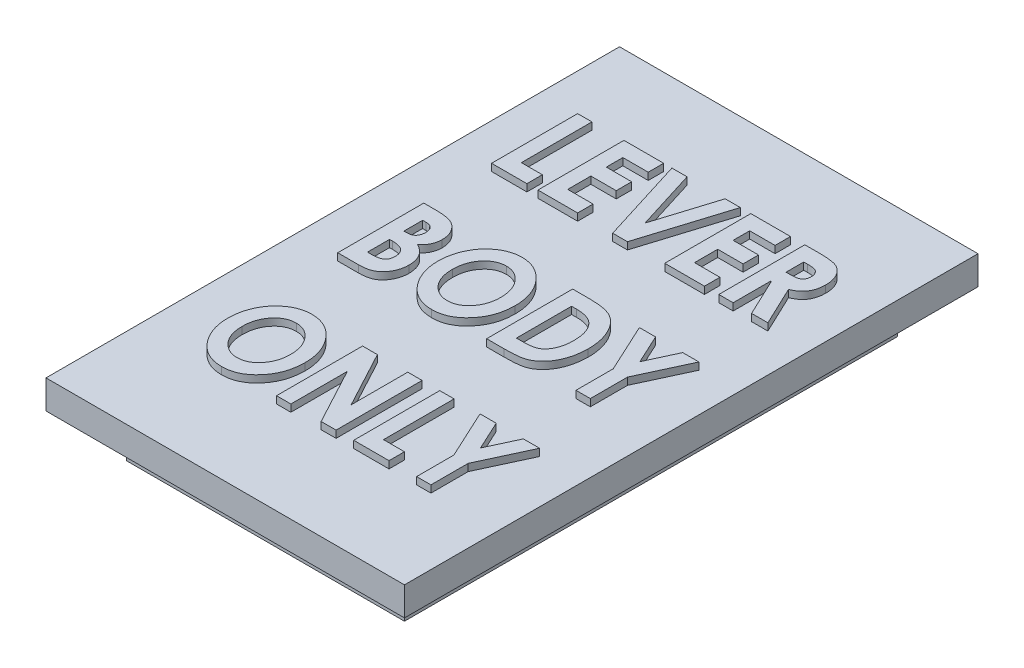
from build123d import *

# Parameters (mm, degrees)
SKETCH1_W           = 19.4
SKETCH1_H           = 34.4
BOSS_EXTRUDE1_DEPTH = 3
SKETCH2_W           = 25
SKETCH2_H           = 40
BOSS_EXTRUDE2_DEPTH = 2
BOSS_EXTRUDE3_DEPTH = 0.5


with BuildPart() as part:
    # Sketch1 → Boss-Extrude1 (new body)
    with BuildSketch(Plane(origin=(0, 0, 0), x_dir=(1, 0, 0), z_dir=(0, 1, 0))):
        Rectangle(SKETCH1_W, SKETCH1_H)
    extrude(amount=BOSS_EXTRUDE1_DEPTH)

    # Sketch2 → Boss-Extrude2 (add)
    with BuildSketch(Plane(origin=(0, 3, 0), x_dir=(1, 0, 0), z_dir=(0, 1, 0))):
        Rectangle(SKETCH2_W, SKETCH2_H)
    extrude(amount=BOSS_EXTRUDE2_DEPTH)

    # Sketch3 → Boss-Extrude3 (add)
    with BuildSketch(Plane(origin=(0, 5, 0), x_dir=(1, 0, 0), z_dir=(0, 1, 0))):
        Polygon((-9.423076923, 14), (-8.423076923, 14), (-8.423076923, 9.076923077), (-6.961538462, 9.076923077), (-6.961538462, 8), (-9.423076923, 8), align=None)
        Polygon((-6.192307692, 14), (-3.423076923, 14), (-3.423076923, 12.923076923), (-5.192307692, 12.923076923), (-5.192307692, 11.769230769), (-3.423076923, 11.769230769), (-3.423076923, 10.692307692), (-5.192307692, 10.692307692), (-5.192307692, 9.076923077), (-3.423076923, 9.076923077), (-3.423076923, 8), (-6.192307692, 8), align=None)
        Polygon((-2.846153846, 14), (-1.788461538, 14), (-0.461538462, 9.737980769), (0.867788462, 14), (1.923076923, 14), (0.051682692, 8), (-0.977163462, 8), align=None)
        Polygon((2.653846154, 14), (5.423076923, 14), (5.423076923, 12.923076923), (3.653846154, 12.923076923), (3.653846154, 11.769230769), (5.423076923, 11.769230769), (5.423076923, 10.692307692), (3.653846154, 10.692307692), (3.653846154, 9.076923077), (5.423076923, 9.076923077), (5.423076923, 8), (2.653846154, 8), align=None)
        with BuildLine():
            Line((6.423076923, 14), (7.495192308, 14))
            add(Edge.make_bspline(
                [(7.495192308, 14), (7.565716082, 13.999692793), (7.702010779, 13.999099082), (7.898391471, 13.990259019), (8.079272988, 13.977728257), (8.244156273, 13.958758313), (8.393014185, 13.933838236), (8.526193833, 13.903624533), (8.644139743, 13.87011321), (8.779050299, 13.815187629), (8.930257846, 13.729159202), (9.092102694, 13.597787753), (9.233816486, 13.436238489), (9.355507645, 13.248692243), (9.455996707, 13.038283275), (9.526259048, 12.806550176), (9.56898116, 12.556866273), (9.574225501, 12.384390756), (9.576923077, 12.295673077)],
                knots=[0, 0, 0, 0, 0.000211552, 0.000408847, 0.00058962, 0.000755402, 0.000906563, 0.001042146, 0.001164983, 0.001273902, 0.001478441, 0.001684363, 0.001896369, 0.002120391, 0.002353186, 0.002593456, 0.002844601, 0.003110617, 0.003110617, 0.003110617, 0.003110617], degree=3))
            add(Edge.make_bspline(
                [(9.576923077, 12.295673077), (9.57634034, 12.248372382), (9.575197559, 12.155612924), (9.562997288, 12.019467998), (9.542424057, 11.889473187), (9.514918602, 11.764865894), (9.479415699, 11.64605475), (9.433945253, 11.533657974), (9.383200458, 11.42639336), (9.322007668, 11.325942603), (9.254082633, 11.231148047), (9.177195351, 11.142737763), (9.093581116, 11.059422992), (8.999749925, 10.983791093), (8.898931748, 10.912490949), (8.789272857, 10.848096085), (8.672313049, 10.788408867), (8.590015205, 10.755003739), (8.548076923, 10.737980769)],
                knots=[0, 0, 0, 0, 0.000141873, 0.000278221, 0.000409627, 0.000536474, 0.000660808, 0.000781108, 0.00089991, 0.001016373, 0.00113346, 0.001249357, 0.001367494, 0.001487072, 0.001610449, 0.001737632, 0.001868249, 0.002003976, 0.002003976, 0.002003976, 0.002003976], degree=3))
            Line((8.548076923, 10.737980769), (9.846153846, 8))
            Line((9.846153846, 8), (8.710336538, 8))
            Line((8.710336538, 8), (7.469951923, 10.615384615))
            Line((7.469951923, 10.615384615), (7.423076923, 10.615384615))
            Line((7.423076923, 10.615384615), (7.423076923, 8))
            Line((7.423076923, 8), (6.423076923, 8))
            Line((6.423076923, 8), (6.423076923, 14))
        make_face()
        with BuildLine():
            Line((7.423076923, 11.692307692), (7.737980769, 11.692307692))
            add(Edge.make_bspline(
                [(7.737980769, 11.692307692), (7.776444427, 11.692888957), (7.850215642, 11.69400379), (7.95624872, 11.699097626), (8.052470782, 11.711523783), (8.139483597, 11.727213836), (8.218081269, 11.745218745), (8.286524629, 11.771018343), (8.346488021, 11.799230102), (8.41266021, 11.84465353), (8.481983468, 11.916603886), (8.538731233, 12.028063417), (8.572097584, 12.161949108), (8.575245837, 12.258603368), (8.576923077, 12.310096154)],
                knots=[0, 0, 0, 0, 0.00011541, 0.000221349, 0.000318252, 0.000406189, 0.000486646, 0.000559658, 0.000625237, 0.000684911, 0.000799674, 0.000920645, 0.001055908, 0.001210134, 0.001210134, 0.001210134, 0.001210134], degree=3))
            add(Edge.make_bspline(
                [(8.576923077, 12.310096154), (8.575743875, 12.341827369), (8.573442756, 12.403748342), (8.556284171, 12.493096474), (8.528812603, 12.576443972), (8.488732703, 12.651576163), (8.440824607, 12.719628017), (8.38404366, 12.777722916), (8.3195226, 12.825220132), (8.244050024, 12.863789384), (8.148509814, 12.891389305), (8.025928454, 12.910559882), (7.87239739, 12.921700941), (7.759634934, 12.92259225), (7.698317308, 12.923076923)],
                knots=[0, 0, 0, 0, 9.5142e-05, 0.000185662, 0.000271941, 0.000357422, 0.000440136, 0.00052088, 0.00059997, 0.000679524, 0.000773812, 0.000896914, 0.001051229, 0.001235158, 0.001235158, 0.001235158, 0.001235158], degree=3))
            Line((7.698317308, 12.923076923), (7.423076923, 12.923076923))
            Line((7.423076923, 12.923076923), (7.423076923, 11.692307692))
        make_face(mode=Mode.SUBTRACT)
        with BuildLine():
            Line((-9.384615385, -2.769230769), (-9.384615385, 3.230769231))
            Line((-9.384615385, 3.230769231), (-8.575721154, 3.230769231))
            add(Edge.make_bspline(
                [(-8.575721154, 3.230769231), (-8.519223397, 3.230779244), (-8.409797524, 3.230798639), (-8.251527984, 3.224137387), (-8.1048841, 3.21575209), (-7.970014332, 3.206007352), (-7.847487459, 3.189714384), (-7.736666137, 3.172301881), (-7.637370877, 3.151126425), (-7.576018233, 3.13259888), (-7.546875, 3.123798077)],
                knots=[0, 0, 0, 0, 0.000169475, 0.000328243, 0.000475119, 0.000610168, 0.000733756, 0.000845793, 0.000946697, 0.001037996, 0.001037996, 0.001037996, 0.001037996], degree=3))
            add(Edge.make_bspline(
                [(-7.546875, 3.123798077), (-7.50895312, 3.111263932), (-7.433889188, 3.086453395), (-7.326939058, 3.037596266), (-7.225590471, 2.982344728), (-7.129952113, 2.91969153), (-7.040650895, 2.848451795), (-6.957806657, 2.76882825), (-6.880642941, 2.682016213), (-6.809888719, 2.588393857), (-6.746163543, 2.488843349), (-6.691041525, 2.384164115), (-6.643730514, 2.27538287), (-6.605222336, 2.161999231), (-6.575442917, 2.044201303), (-6.55329253, 1.922185523), (-6.541792023, 1.795492904), (-6.539584043, 1.709554987), (-6.538461538, 1.665865385)],
                knots=[0, 0, 0, 0, 0.000119741, 0.000237019, 0.000352128, 0.000465803, 0.000579555, 0.000694318, 0.000810103, 0.000927652, 0.001046015, 0.0011643, 0.001282192, 0.00140154, 0.001523101, 0.001646408, 0.001773181, 0.001904279, 0.001904279, 0.001904279, 0.001904279], degree=3))
            add(Edge.make_bspline(
                [(-6.538461538, 1.665865385), (-6.54014369, 1.609696432), (-6.543451703, 1.499238068), (-6.567568843, 1.337455146), (-6.608999868, 1.183701436), (-6.665359697, 1.036786187), (-6.741253748, 0.895929761), (-6.83855043, 0.761798645), (-6.954664737, 0.630153137), (-7.044734275, 0.550721859), (-7.091346154, 0.509615385)],
                knots=[0, 0, 0, 0, 0.000168479, 0.000331321, 0.000489341, 0.00064536, 0.000802389, 0.000967818, 0.001141495, 0.001327778, 0.001327778, 0.001327778, 0.001327778], degree=3))
            add(Edge.make_bspline(
                [(-7.091346154, 0.509615385), (-7.051817001, 0.488039316), (-6.974329897, 0.445744783), (-6.864843951, 0.375730957), (-6.763143382, 0.30209537), (-6.669513415, 0.224658462), (-6.585120992, 0.141952308), (-6.50742828, 0.056843737), (-6.439049013, -0.033518199), (-6.35862584, -0.159121332), (-6.275357097, -0.328043204), (-6.204521409, -0.547378676), (-6.161764955, -0.784402781), (-6.156537908, -0.948135201), (-6.153846154, -1.032451923)],
                knots=[0, 0, 0, 0, 0.000135071, 0.000264773, 0.000389547, 0.000511582, 0.000628879, 0.000743768, 0.000856992, 0.00096835, 0.001190884, 0.001419698, 0.001657818, 0.001910634, 0.001910634, 0.001910634, 0.001910634], degree=3))
            add(Edge.make_bspline(
                [(-6.153846154, -1.032451923), (-6.156594668, -1.114374148), (-6.162007816, -1.275718466), (-6.205603009, -1.511862417), (-6.274976299, -1.737619757), (-6.373689267, -1.948466839), (-6.492493121, -2.141473397), (-6.630267328, -2.310195479), (-6.784600771, -2.453005097), (-6.927536116, -2.550326258), (-7.051341578, -2.615741234), (-7.154037336, -2.655032792), (-7.263266757, -2.692615296), (-7.382457851, -2.718769322), (-7.508966525, -2.742305299), (-7.644750132, -2.757242352), (-7.788316244, -2.767039015), (-7.887001552, -2.768488864), (-7.9375, -2.769230769)],
                knots=[0, 0, 0, 0, 0.000245616, 0.000483736, 0.000717911, 0.000952372, 0.001180171, 0.00139624, 0.001603786, 0.001808809, 0.001913099, 0.002023133, 0.002138298, 0.002259287, 0.002388721, 0.00252424, 0.002668791, 0.002820277, 0.002820277, 0.002820277, 0.002820277], degree=3))
            Line((-7.9375, -2.769230769), (-9.384615385, -2.769230769))
        make_face()
        with BuildLine():
            Line((-8.384615385, 2.153846154), (-8.384615385, 0.846153846))
            Line((-8.384615385, 0.846153846), (-8.1875, 0.846153846))
            add(Edge.make_bspline(
                [(-8.1875, 0.846153846), (-8.135970161, 0.847719424), (-8.038368132, 0.850684766), (-7.902730464, 0.886293702), (-7.786785678, 0.94260981), (-7.694575497, 1.024731845), (-7.624115694, 1.125730918), (-7.573233379, 1.24335541), (-7.543074265, 1.377507101), (-7.540043851, 1.472194289), (-7.538461538, 1.521634615)],
                knots=[0, 0, 0, 0, 0.000154226, 0.000292118, 0.00041736, 0.000537438, 0.000658158, 0.000784102, 0.000919685, 0.001067834, 0.001067834, 0.001067834, 0.001067834], degree=3))
            add(Edge.make_bspline(
                [(-7.538461538, 1.521634615), (-7.540052556, 1.56789856), (-7.543089778, 1.656215571), (-7.57299262, 1.780890624), (-7.619188768, 1.891842809), (-7.687807945, 1.985656031), (-7.775113175, 2.062884387), (-7.883771389, 2.117442112), (-8.012347939, 2.148305748), (-8.103989639, 2.151924748), (-8.152644231, 2.153846154)],
                knots=[0, 0, 0, 0, 0.000138555, 0.000264499, 0.000382392, 0.000496827, 0.000610121, 0.000728917, 0.000857764, 0.001003598, 0.001003598, 0.001003598, 0.001003598], degree=3))
            Line((-8.152644231, 2.153846154), (-8.384615385, 2.153846154))
        make_face(mode=Mode.SUBTRACT)
        with BuildLine():
            Line((-8.384615385, -0.153846154), (-8.384615385, -1.692307692))
            Line((-8.384615385, -1.692307692), (-8.149038462, -1.692307692))
            add(Edge.make_bspline(
                [(-8.149038462, -1.692307692), (-8.102152584, -1.691956339), (-8.011902957, -1.691280027), (-7.882664911, -1.683138923), (-7.765564262, -1.668551254), (-7.660521927, -1.650061426), (-7.567112784, -1.624886702), (-7.485660793, -1.594120202), (-7.415518355, -1.55832623), (-7.340143284, -1.501796888), (-7.264139712, -1.415306015), (-7.198036828, -1.291730914), (-7.161056072, -1.146693885), (-7.156332131, -1.044280006), (-7.153846154, -0.990384615)],
                knots=[0, 0, 0, 0, 0.000140646, 0.000270726, 0.000388201, 0.000494522, 0.00059045, 0.000677951, 0.000755371, 0.000825804, 0.000959455, 0.001097111, 0.001242588, 0.001404188, 0.001404188, 0.001404188, 0.001404188], degree=3))
            add(Edge.make_bspline(
                [(-7.153846154, -0.990384615), (-7.154522301, -0.95870714), (-7.155836009, -0.897159971), (-7.166501756, -0.807286972), (-7.186032168, -0.722879066), (-7.212126436, -0.64337779), (-7.246194974, -0.56930711), (-7.287286468, -0.500406649), (-7.335682454, -0.435985363), (-7.392431253, -0.376933657), (-7.457758736, -0.323347643), (-7.533147443, -0.277703731), (-7.618221654, -0.238872555), (-7.713680672, -0.208579186), (-7.818294802, -0.182607853), (-7.933141109, -0.167110862), (-8.057456704, -0.15554585), (-8.143798234, -0.154427681), (-8.188701923, -0.153846154)],
                knots=[0, 0, 0, 0, 9.502e-05, 0.000184618, 0.000270923, 0.00035454, 0.000435213, 0.000514984, 0.000594793, 0.000676399, 0.000760121, 0.000847523, 0.000940032, 0.001039994, 0.001147565, 0.001262981, 0.001387251, 0.001521914, 0.001521914, 0.001521914, 0.001521914], degree=3))
            Line((-8.188701923, -0.153846154), (-8.384615385, -0.153846154))
        make_face(mode=Mode.SUBTRACT)
        with BuildLine():
            add(Edge.make_bspline(
                [(-2.681490385, 3.384615385), (-2.591164255, 3.381950448), (-2.413053702, 3.376695563), (-2.150935296, 3.331641838), (-1.898422683, 3.259621782), (-1.655432938, 3.158133184), (-1.423023311, 3.026463346), (-1.199831022, 2.867405077), (-0.987681743, 2.677594102), (-0.786611524, 2.463531782), (-0.602747581, 2.228210672), (-0.440912701, 1.977818944), (-0.304958626, 1.71427333), (-0.191677454, 1.439295165), (-0.107377357, 1.150012365), (-0.044505324, 0.849166271), (-0.006361322, 0.535035636), (-0.002145075, 0.321420219), (0, 0.212740385)],
                knots=[0, 0, 0, 0, 0.000270817, 0.000534013, 0.000795362, 0.001057196, 0.001321969, 0.001595123, 0.001877797, 0.002174555, 0.002475096, 0.002772484, 0.003067612, 0.003363571, 0.003663238, 0.00397015, 0.004284863, 0.004610806, 0.004610806, 0.004610806, 0.004610806], degree=3))
            add(Edge.make_bspline(
                [(0, 0.212740385), (-0.002088915, 0.105247644), (-0.006201855, -0.106398751), (-0.045221542, -0.416976174), (-0.104295057, -0.715660813), (-0.189739524, -1.001531272), (-0.301208269, -1.27440565), (-0.435916328, -1.535008127), (-0.595885479, -1.78241769), (-0.776594377, -2.015165241), (-0.976141215, -2.226057211), (-1.186616561, -2.413170521), (-1.409169908, -2.569987921), (-1.641058163, -2.700240621), (-1.884402526, -2.800689766), (-2.138549561, -2.87168519), (-2.403181874, -2.914722806), (-2.583173366, -2.920269419), (-2.674278846, -2.923076923)],
                knots=[0, 0, 0, 0, 0.00032234, 0.000634666, 0.000937563, 0.001234926, 0.001528205, 0.001820646, 0.002113701, 0.002410868, 0.002703353, 0.002983535, 0.003254317, 0.003518502, 0.003779876, 0.004042052, 0.004308614, 0.004581831, 0.004581831, 0.004581831, 0.004581831], degree=3))
            add(Edge.make_bspline(
                [(-2.674278846, -2.923076923), (-2.769832133, -2.920581663), (-2.957607937, -2.915678122), (-3.232216693, -2.868746866), (-3.495578733, -2.798016906), (-3.744950499, -2.692976314), (-3.983023867, -2.56133545), (-4.207324744, -2.398616705), (-4.419629753, -2.207360087), (-4.61740351, -1.990106351), (-4.795603935, -1.752072268), (-4.954734891, -1.501842605), (-5.086628681, -1.23881097), (-5.195469629, -0.965337827), (-5.281246432, -0.681596897), (-5.340894687, -0.386229456), (-5.377967896, -0.08027681), (-5.382378521, 0.127697972), (-5.384615385, 0.233173077)],
                knots=[0, 0, 0, 0, 0.000286421, 0.000562858, 0.000833462, 0.001102878, 0.001372433, 0.001647964, 0.001932239, 0.002228312, 0.002527832, 0.002823283, 0.003116769, 0.00340915, 0.003705363, 0.004004726, 0.004312136, 0.004628471, 0.004628471, 0.004628471, 0.004628471], degree=3))
            add(Edge.make_bspline(
                [(-5.384615385, 0.233173077), (-5.383397255, 0.30412125), (-5.380978251, 0.445012578), (-5.363559938, 0.654028624), (-5.336563491, 0.858839828), (-5.296284183, 1.058936932), (-5.246020956, 1.254824212), (-5.184646307, 1.446827975), (-5.111243652, 1.634154789), (-5.026883646, 1.816481702), (-4.934554703, 1.992797911), (-4.829887388, 2.158617406), (-4.7198769, 2.316739867), (-4.600523611, 2.464855439), (-4.472485383, 2.603826429), (-4.336040378, 2.733242875), (-4.190674232, 2.852797057), (-4.038645393, 2.962905002), (-3.881121848, 3.062968203), (-3.717969059, 3.147598125), (-3.553359515, 3.222401666), (-3.38430353, 3.280245886), (-3.213302631, 3.328610358), (-3.038508742, 3.359704127), (-2.861149416, 3.381937947), (-2.741657833, 3.383718716), (-2.681490385, 3.384615385)],
                knots=[0, 0, 0, 0, 0.000212825, 0.000422636, 0.000628824, 0.000832248, 0.00103456, 0.001235256, 0.001436581, 0.001637716, 0.00183773, 0.002033168, 0.002225569, 0.002415344, 0.002603324, 0.002792069, 0.002979048, 0.003167535, 0.003354947, 0.003538278, 0.003718527, 0.003896805, 0.004073798, 0.004251072, 0.004428933, 0.004609321, 0.004609321, 0.004609321, 0.004609321], degree=3))
        make_face()
        with BuildLine():
            add(Edge.make_bspline(
                [(-2.695913462, 2.307692308), (-2.75452499, 2.305834514), (-2.870007443, 2.302174097), (-3.039283894, 2.273466331), (-3.20151597, 2.228568585), (-3.355706089, 2.161807002), (-3.503771585, 2.079355677), (-3.64442309, 1.977129802), (-3.776716275, 1.855993105), (-3.900931391, 1.718260122), (-4.014467278, 1.566873194), (-4.113601374, 1.403295329), (-4.197576612, 1.23024597), (-4.266814261, 1.047323784), (-4.319241261, 0.853976084), (-4.357515284, 0.651074609), (-4.380988101, 0.438052793), (-4.383388449, 0.2929296), (-4.384615385, 0.21875)],
                knots=[0, 0, 0, 0, 0.000175744, 0.000346269, 0.000513677, 0.000679547, 0.000849057, 0.001021196, 0.001199875, 0.001386235, 0.00157686, 0.001766707, 0.00195915, 0.00215314, 0.002352587, 0.002559321, 0.002772089, 0.002994562, 0.002994562, 0.002994562, 0.002994562], degree=3))
            add(Edge.make_bspline(
                [(-4.384615385, 0.21875), (-4.382848022, 0.136530174), (-4.379388111, -0.024428948), (-4.350074025, -0.258969355), (-4.30251585, -0.480508231), (-4.234317519, -0.688288922), (-4.150087364, -0.88446937), (-4.042530646, -1.065108406), (-3.919200163, -1.234959431), (-3.821053231, -1.334496708), (-3.771634615, -1.384615385)],
                knots=[0, 0, 0, 0, 0.000246582, 0.000482725, 0.00070787, 0.000925282, 0.001137873, 0.001346897, 0.001554833, 0.001765715, 0.001765715, 0.001765715, 0.001765715], degree=3))
            add(Edge.make_bspline(
                [(-3.771634615, -1.384615385), (-3.731837841, -1.421463544), (-3.653562156, -1.493939642), (-3.526612245, -1.587353146), (-3.396276722, -1.667705174), (-3.260952816, -1.732953736), (-3.121161001, -1.783563638), (-2.97703852, -1.819784526), (-2.828822436, -1.842065954), (-2.728442066, -1.844784584), (-2.677884615, -1.846153846)],
                knots=[0, 0, 0, 0, 0.000162598, 0.000319811, 0.000471938, 0.000621383, 0.000769664, 0.000917168, 0.001066579, 0.001218193, 0.001218193, 0.001218193, 0.001218193], degree=3))
            add(Edge.make_bspline(
                [(-2.677884615, -1.846153846), (-2.620885262, -1.844245159), (-2.508212271, -1.840472179), (-2.342268753, -1.812214094), (-2.183016444, -1.765133757), (-2.029993616, -1.69961398), (-1.883813441, -1.615024297), (-1.745177404, -1.510334429), (-1.612583561, -1.388162178), (-1.487284322, -1.249529618), (-1.372515629, -1.096951333), (-1.273069628, -0.933153092), (-1.187772272, -0.761321431), (-1.119851565, -0.5802274), (-1.065042059, -0.390695041), (-1.02731772, -0.192322527), (-1.003616847, 0.014644912), (-1.001221641, 0.155382335), (-1, 0.227163462)],
                knots=[0, 0, 0, 0, 0.000170944, 0.000337912, 0.000503345, 0.00066811, 0.000836125, 0.001008722, 0.001188211, 0.001376269, 0.001568577, 0.001760075, 0.001950359, 0.002143225, 0.002339526, 0.002541538, 0.002748332, 0.002963597, 0.002963597, 0.002963597, 0.002963597], degree=3))
            add(Edge.make_bspline(
                [(-1, 0.227163462), (-1.001105024, 0.298556519), (-1.003278245, 0.438963358), (-1.028748392, 0.644997304), (-1.0664444, 0.842942952), (-1.120638738, 1.032478462), (-1.190901893, 1.213154832), (-1.274756083, 1.386500691), (-1.376722309, 1.549839608), (-1.491105558, 1.704321996), (-1.617047299, 1.844833153), (-1.751263235, 1.96814392), (-1.890660109, 2.074335652), (-2.03900953, 2.158822306), (-2.19380645, 2.225419685), (-2.355330999, 2.274048129), (-2.523872091, 2.301928637), (-2.638121272, 2.305756174), (-2.695913462, 2.307692308)],
                knots=[0, 0, 0, 0, 0.000214064, 0.000420994, 0.000621826, 0.000818127, 0.001011423, 0.001202786, 0.001394913, 0.001588184, 0.001778832, 0.001960019, 0.002134298, 0.002303355, 0.002470803, 0.002638883, 0.002808222, 0.002981566, 0.002981566, 0.002981566, 0.002981566], degree=3))
        make_face(mode=Mode.SUBTRACT)
        with BuildLine():
            Line((1, 3.230769231), (2.181490385, 3.230769231))
            add(Edge.make_bspline(
                [(2.181490385, 3.230769231), (2.273662624, 3.230018527), (2.452140179, 3.228564904), (2.710393115, 3.212571589), (2.950653338, 3.187617422), (3.172775389, 3.153620317), (3.376600674, 3.108521827), (3.561638159, 3.05160638), (3.728999806, 2.986467723), (3.880031096, 2.909529867), (4.017349051, 2.819759858), (4.147970469, 2.719779993), (4.271681185, 2.606635016), (4.388706925, 2.480272395), (4.500930858, 2.342416004), (4.604733453, 2.18979083), (4.704961156, 2.026743274), (4.797156201, 1.851227775), (4.880823071, 1.665888942), (4.954755281, 1.471876669), (5.015462019, 1.269605012), (5.066095374, 1.059771897), (5.105913195, 0.842333654), (5.132906697, 0.617126484), (5.150311385, 0.384488016), (5.152654886, 0.226794608), (5.153846154, 0.146634615)],
                knots=[0, 0, 0, 0, 0.000276484, 0.00053537, 0.00077588, 0.001000951, 0.001209148, 0.001401523, 0.001581194, 0.001747294, 0.001908987, 0.002072701, 0.002240303, 0.002411234, 0.002588997, 0.002773032, 0.002964531, 0.003162921, 0.003367336, 0.00357427, 0.003785292, 0.004000433, 0.004221567, 0.00444802, 0.004680601, 0.004921061, 0.004921061, 0.004921061, 0.004921061], degree=3))
            add(Edge.make_bspline(
                [(5.153846154, 0.146634615), (5.151858115, 0.0335282), (5.14794752, -0.188959076), (5.107595895, -0.515181604), (5.046576806, -0.828522164), (4.956701758, -1.12497884), (4.849292817, -1.403902526), (4.718727466, -1.65833924), (4.570766889, -1.889446894), (4.402666348, -2.092582074), (4.222578494, -2.269348115), (4.034564982, -2.419299158), (3.837412, -2.538191847), (3.663126617, -2.613768166), (3.512198318, -2.660756161), (3.380002074, -2.688298026), (3.229732437, -2.713866892), (3.059947294, -2.733240761), (2.871672849, -2.750750502), (2.664333302, -2.760272298), (2.438361617, -2.768142464), (2.281258764, -2.768858316), (2.199519231, -2.769230769)],
                knots=[0, 0, 0, 0, 0.000339155, 0.000667139, 0.00098465, 0.001295713, 0.001595243, 0.001880139, 0.002152181, 0.002416877, 0.002669306, 0.002908078, 0.003136674, 0.003357939, 0.003476174, 0.003610322, 0.003762668, 0.003933366, 0.004122817, 0.00432983, 0.004555907, 0.004801111, 0.004801111, 0.004801111, 0.004801111], degree=3))
            Line((2.199519231, -2.769230769), (1, -2.769230769))
            Line((1, -2.769230769), (1, 3.230769231))
        make_face()
        with BuildLine():
            Line((2, 2.153846154), (2, -1.692307692))
            Line((2, -1.692307692), (2.462740385, -1.692307692))
            add(Edge.make_bspline(
                [(2.462740385, -1.692307692), (2.517653835, -1.692166734), (2.623967915, -1.691893834), (2.777362761, -1.680756617), (2.919664819, -1.669431542), (3.049398849, -1.647969499), (3.168061034, -1.624329888), (3.273752663, -1.590478331), (3.369877214, -1.556115388), (3.481114883, -1.497199737), (3.607248397, -1.404370036), (3.741252593, -1.263984054), (3.861057484, -1.092879835), (3.964545896, -0.891987897), (4.049849511, -0.663479533), (4.110131458, -0.408786759), (4.148024536, -0.12974435), (4.151855283, 0.064773085), (4.153846154, 0.165865385)],
                knots=[0, 0, 0, 0, 0.000164681, 0.000318827, 0.000461269, 0.000592675, 0.000713138, 0.000823773, 0.000925341, 0.001018883, 0.001200389, 0.001392494, 0.001598584, 0.00182491, 0.002068699, 0.00232844, 0.002608573, 0.002911696, 0.002911696, 0.002911696, 0.002911696], degree=3))
            add(Edge.make_bspline(
                [(4.153846154, 0.165865385), (4.152495136, 0.244435082), (4.1498635, 0.397480266), (4.128484793, 0.620607744), (4.090697103, 0.830097192), (4.041527867, 1.026945632), (3.974799673, 1.208921856), (3.895097129, 1.377890486), (3.801027416, 1.533966995), (3.725085083, 1.627022337), (3.6875, 1.673076923)],
                knots=[0, 0, 0, 0, 0.000235687, 0.000459093, 0.000671521, 0.000873833, 0.001066988, 0.001251932, 0.001433745, 0.001611897, 0.001611897, 0.001611897, 0.001611897], degree=3))
            add(Edge.make_bspline(
                [(3.6875, 1.673076923), (3.650898549, 1.711890109), (3.57734728, 1.789885899), (3.445929742, 1.887300419), (3.29996862, 1.970703331), (3.137291035, 2.037553341), (2.959811246, 2.090721696), (2.766409422, 2.126870944), (2.557477297, 2.150488949), (2.412730346, 2.152700435), (2.337740385, 2.153846154)],
                knots=[0, 0, 0, 0, 0.000159779, 0.000321079, 0.000488496, 0.000663052, 0.00084748, 0.001043364, 0.001252547, 0.001477422, 0.001477422, 0.001477422, 0.001477422], degree=3))
            Line((2.337740385, 2.153846154), (2, 2.153846154))
        make_face(mode=Mode.SUBTRACT)
        Polygon((5.653846154, 3.230769231), (6.782451923, 3.230769231), (7.730769231, 1.1875), (8.677884615, 3.230769231), (9.807692308, 3.230769231), (8.230769231, -0.170673077), (8.230769231, -2.769230769), (7.230769231, -2.769230769), (7.230769231, -0.170673077), align=None)
        with BuildLine():
            add(Edge.make_bspline(
                [(-6.566105769, -7.384615385), (-6.475779639, -7.387280322), (-6.297669086, -7.392535206), (-6.03555068, -7.437588931), (-5.783038067, -7.509608987), (-5.540048322, -7.611097585), (-5.307638695, -7.742767423), (-5.084446406, -7.901825692), (-4.872297127, -8.091636667), (-4.671226909, -8.305698987), (-4.487362966, -8.541020097), (-4.325528086, -8.791411825), (-4.189574011, -9.05495744), (-4.076292839, -9.329935604), (-3.991992742, -9.619218405), (-3.929120708, -9.920064498), (-3.890976707, -10.234195133), (-3.886760459, -10.44781055), (-3.884615385, -10.556490385)],
                knots=[0, 0, 0, 0, 0.000270817, 0.000534013, 0.000795362, 0.001057196, 0.001321969, 0.001595123, 0.001877797, 0.002174555, 0.002475096, 0.002772484, 0.003067612, 0.003363571, 0.003663238, 0.00397015, 0.004284863, 0.004610806, 0.004610806, 0.004610806, 0.004610806], degree=3))
            add(Edge.make_bspline(
                [(-3.884615385, -10.556490385), (-3.886704299, -10.663983125), (-3.89081724, -10.87562952), (-3.929836927, -11.186206943), (-3.988910442, -11.484891582), (-4.074354909, -11.770762041), (-4.185823654, -12.043636419), (-4.320531712, -12.304238896), (-4.480500864, -12.55164846), (-4.661209762, -12.78439601), (-4.8607566, -12.995287981), (-5.071231945, -13.18240129), (-5.293785292, -13.33921869), (-5.525673548, -13.46947139), (-5.76901791, -13.569920535), (-6.023164945, -13.64091596), (-6.287797259, -13.683953575), (-6.46778875, -13.689500188), (-6.558894231, -13.692307692)],
                knots=[0, 0, 0, 0, 0.00032234, 0.000634666, 0.000937563, 0.001234926, 0.001528205, 0.001820646, 0.002113701, 0.002410868, 0.002703353, 0.002983535, 0.003254317, 0.003518502, 0.003779876, 0.004042052, 0.004308614, 0.004581831, 0.004581831, 0.004581831, 0.004581831], degree=3))
            add(Edge.make_bspline(
                [(-6.558894231, -13.692307692), (-6.654447518, -13.689812432), (-6.842223322, -13.684908892), (-7.116832078, -13.637977635), (-7.380194118, -13.567247676), (-7.629565883, -13.462207083), (-7.867639251, -13.330566219), (-8.091940129, -13.167847474), (-8.304245137, -12.976590856), (-8.502018894, -12.759337121), (-8.68021932, -12.521303037), (-8.839350275, -12.271073374), (-8.971244066, -12.008041739), (-9.080085014, -11.734568596), (-9.165861817, -11.450827666), (-9.225510071, -11.155460225), (-9.262583281, -10.849507579), (-9.266993906, -10.641532797), (-9.269230769, -10.536057692)],
                knots=[0, 0, 0, 0, 0.000286421, 0.000562858, 0.000833462, 0.001102878, 0.001372433, 0.001647964, 0.001932239, 0.002228312, 0.002527832, 0.002823283, 0.003116769, 0.00340915, 0.003705363, 0.004004726, 0.004312136, 0.004628471, 0.004628471, 0.004628471, 0.004628471], degree=3))
            add(Edge.make_bspline(
                [(-9.269230769, -10.536057692), (-9.26801264, -10.465109519), (-9.265593636, -10.324218191), (-9.248175323, -10.115202145), (-9.221178876, -9.910390942), (-9.180899568, -9.710293837), (-9.130636341, -9.514406557), (-9.069261691, -9.322402794), (-8.995859037, -9.13507598), (-8.911499031, -8.952749067), (-8.819170087, -8.776432858), (-8.714502773, -8.610613363), (-8.604492285, -8.452490902), (-8.485138995, -8.304375331), (-8.357100768, -8.16540434), (-8.220655763, -8.035987894), (-8.075289616, -7.916433712), (-7.923260778, -7.806325767), (-7.765737233, -7.706262566), (-7.602584443, -7.621632644), (-7.4379749, -7.546829104), (-7.268918915, -7.488984884), (-7.097918016, -7.440620411), (-6.923124127, -7.409526642), (-6.745764801, -7.387292822), (-6.626273217, -7.385512053), (-6.566105769, -7.384615385)],
                knots=[0, 0, 0, 0, 0.000212825, 0.000422636, 0.000628824, 0.000832248, 0.00103456, 0.001235256, 0.001436581, 0.001637716, 0.00183773, 0.002033168, 0.002225569, 0.002415344, 0.002603324, 0.002792069, 0.002979048, 0.003167535, 0.003354947, 0.003538278, 0.003718527, 0.003896805, 0.004073798, 0.004251072, 0.004428933, 0.004609321, 0.004609321, 0.004609321, 0.004609321], degree=3))
        make_face()
        with BuildLine():
            add(Edge.make_bspline(
                [(-6.580528846, -8.461538462), (-6.639140374, -8.463396255), (-6.754622827, -8.467056672), (-6.923899279, -8.495764438), (-7.086131354, -8.540662184), (-7.240321474, -8.607423768), (-7.388386969, -8.689875092), (-7.529038475, -8.792100967), (-7.66133166, -8.913237664), (-7.785546776, -9.050970647), (-7.899082663, -9.202357575), (-7.998216759, -9.36593544), (-8.082191996, -9.538984799), (-8.151429645, -9.721906985), (-8.203856646, -9.915254685), (-8.242130669, -10.118156161), (-8.265603486, -10.331177977), (-8.268003834, -10.476301169), (-8.269230769, -10.550480769)],
                knots=[0, 0, 0, 0, 0.000175744, 0.000346269, 0.000513677, 0.000679547, 0.000849057, 0.001021196, 0.001199875, 0.001386235, 0.00157686, 0.001766707, 0.00195915, 0.00215314, 0.002352587, 0.002559321, 0.002772089, 0.002994562, 0.002994562, 0.002994562, 0.002994562], degree=3))
            add(Edge.make_bspline(
                [(-8.269230769, -10.550480769), (-8.267463406, -10.632700595), (-8.264003496, -10.793659717), (-8.234689409, -11.028200124), (-8.187131235, -11.249739), (-8.118932904, -11.457519691), (-8.034702749, -11.65370014), (-7.92714603, -11.834339175), (-7.803815548, -12.004190201), (-7.705668616, -12.103727477), (-7.65625, -12.153846154)],
                knots=[0, 0, 0, 0, 0.000246582, 0.000482725, 0.00070787, 0.000925282, 0.001137873, 0.001346897, 0.001554833, 0.001765715, 0.001765715, 0.001765715, 0.001765715], degree=3))
            add(Edge.make_bspline(
                [(-7.65625, -12.153846154), (-7.616453226, -12.190694313), (-7.53817754, -12.263170412), (-7.41122763, -12.356583915), (-7.280892106, -12.436935943), (-7.1455682, -12.502184505), (-7.005776385, -12.552794407), (-6.861653905, -12.589015295), (-6.713437821, -12.611296723), (-6.61305745, -12.614015354), (-6.5625, -12.615384615)],
                knots=[0, 0, 0, 0, 0.000162598, 0.000319811, 0.000471938, 0.000621383, 0.000769664, 0.000917168, 0.001066579, 0.001218193, 0.001218193, 0.001218193, 0.001218193], degree=3))
            add(Edge.make_bspline(
                [(-6.5625, -12.615384615), (-6.505500647, -12.613475929), (-6.392827655, -12.609702948), (-6.226884138, -12.581444864), (-6.067631828, -12.534364526), (-5.914609001, -12.468844749), (-5.768428826, -12.384255066), (-5.629792788, -12.279565199), (-5.497198945, -12.157392947), (-5.371899706, -12.018760387), (-5.257131014, -11.866182102), (-5.157685012, -11.702383861), (-5.072387657, -11.530552201), (-5.00446695, -11.349458169), (-4.949657443, -11.159925811), (-4.911933105, -10.961553296), (-4.888232232, -10.754585857), (-4.885837026, -10.613848434), (-4.884615385, -10.542067308)],
                knots=[0, 0, 0, 0, 0.000170944, 0.000337912, 0.000503345, 0.00066811, 0.000836125, 0.001008722, 0.001188211, 0.001376269, 0.001568577, 0.001760075, 0.001950359, 0.002143225, 0.002339526, 0.002541538, 0.002748332, 0.002963597, 0.002963597, 0.002963597, 0.002963597], degree=3))
            add(Edge.make_bspline(
                [(-4.884615385, -10.542067308), (-4.885720408, -10.47067425), (-4.887893629, -10.330267412), (-4.913363777, -10.124233465), (-4.951059784, -9.926287818), (-5.005254122, -9.736752307), (-5.075517278, -9.556075938), (-5.159371467, -9.382730078), (-5.261337693, -9.219391162), (-5.375720943, -9.064908773), (-5.501662684, -8.924397616), (-5.635878619, -8.801086849), (-5.775275494, -8.694895117), (-5.923624914, -8.610408463), (-6.078421835, -8.543811084), (-6.239946383, -8.495182641), (-6.408487476, -8.467302133), (-6.522736657, -8.463474596), (-6.580528846, -8.461538462)],
                knots=[0, 0, 0, 0, 0.000214064, 0.000420994, 0.000621826, 0.000818127, 0.001011423, 0.001202786, 0.001394913, 0.001588184, 0.001778832, 0.001960019, 0.002134298, 0.002303355, 0.002470803, 0.002638883, 0.002808222, 0.002981566, 0.002981566, 0.002981566, 0.002981566], degree=3))
        make_face(mode=Mode.SUBTRACT)
        Polygon((-2.884615385, -7.538461538), (-1.848557692, -7.538461538), (0.269230769, -11.486778846), (0.269230769, -7.538461538), (1.269230769, -7.538461538), (1.269230769, -13.538461538), (0.227163462, -13.538461538), (-1.884615385, -9.602163462), (-1.884615385, -13.538461538), (-2.884615385, -13.538461538), align=None)
        Polygon((2.5, -7.538461538), (3.5, -7.538461538), (3.5, -12.461538462), (4.961538462, -12.461538462), (4.961538462, -13.538461538), (2.5, -13.538461538), align=None)
        Polygon((5.307692308, -7.538461538), (6.436298077, -7.538461538), (7.384615385, -9.581730769), (8.331730769, -7.538461538), (9.461538462, -7.538461538), (7.884615385, -10.939903846), (7.884615385, -13.538461538), (6.884615385, -13.538461538), (6.884615385, -10.939903846), align=None)
    extrude(amount=BOSS_EXTRUDE3_DEPTH)


solid = part.part
